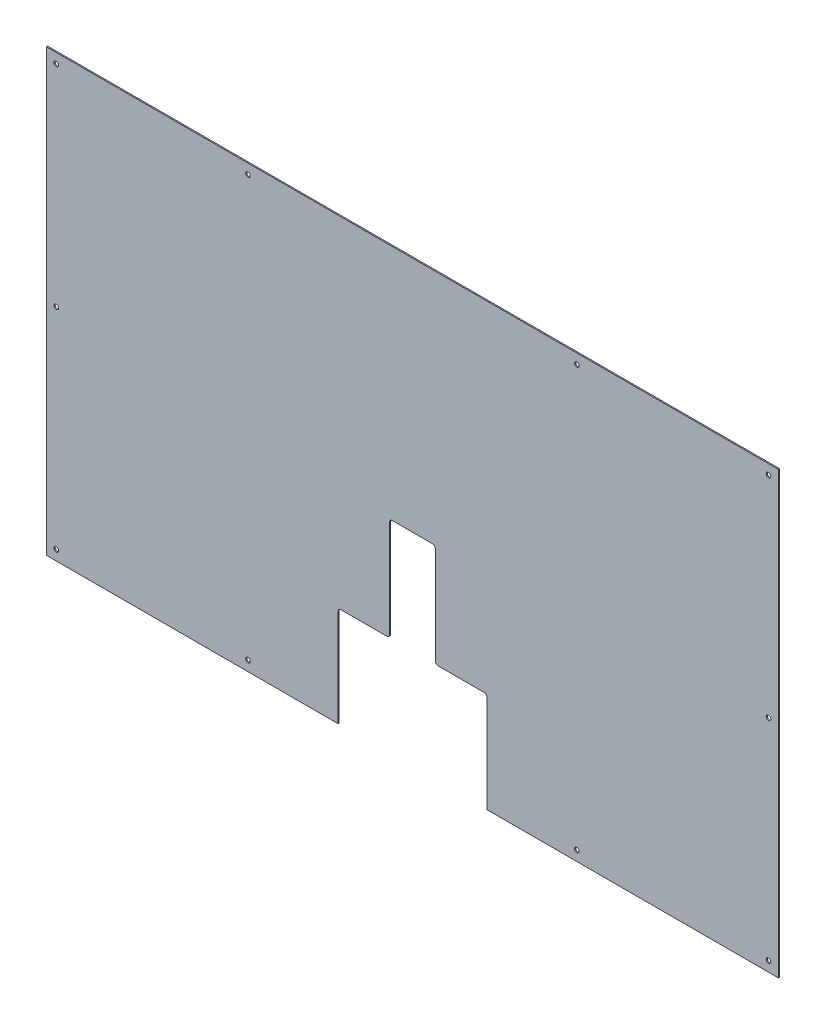
from build123d import *

# Parameters (mm, degrees)
SKETCH1_R           = 4
BOSS_EXTRUDE1_DEPTH = 2


with BuildPart() as part:
    # Sketch1 → Boss-Extrude1 (new body)
    with BuildSketch(Plane.XY):
        with BuildLine():
            Line((0, 0), (0, 770))
            Line((0, 770), (1280, 770))
            Line((1280, 770), (1280, 0))
            Line((1280, 0), (770, 0))
            Line((770, 0), (770, 170))
            ThreePointArc((770, 170), (768.535533906, 173.535533906), (765, 175))
            Line((765, 175), (685, 175))
            ThreePointArc((685, 175), (681.464466094, 176.464466094), (680, 180))
            Line((680, 180), (680, 350))
            ThreePointArc((680, 350), (678.535533906, 353.535533906), (675, 355))
            Line((675, 355), (605, 355))
            ThreePointArc((605, 355), (601.464466094, 353.535533906), (600, 350))
            Line((600, 350), (600, 180))
            ThreePointArc((600, 180), (598.535533906, 176.464466094), (595, 175))
            Line((595, 175), (515, 175))
            ThreePointArc((515, 175), (511.464466094, 173.535533906), (510, 170))
            Line((510, 170), (510, 0))
            Line((510, 0), (0, 0))
        make_face()
        with Locations((17.5, 752.5)):
            Circle(SKETCH1_R, mode=Mode.SUBTRACT)
        with Locations(Location((1262.5, 752.5, 0), (0, 0, 180))):  # turned: the seam where the file's is
            Circle(SKETCH1_R, mode=Mode.SUBTRACT)
        with Locations((1262.5, 17.5)):
            Circle(SKETCH1_R, mode=Mode.SUBTRACT)
        with Locations(Location((17.5, 17.5, 0), (0, 0, 180))):  # turned: the seam where the file's is
            Circle(SKETCH1_R, mode=Mode.SUBTRACT)
        with Locations((352.5, 752.5)):
            Circle(SKETCH1_R, mode=Mode.SUBTRACT)
        with Locations(Location((927.5, 752.5, 0), (0, 0, 180))):  # turned: the seam where the file's is
            Circle(SKETCH1_R, mode=Mode.SUBTRACT)
        with Locations((927.5, 17.5)):
            Circle(SKETCH1_R, mode=Mode.SUBTRACT)
        with Locations(Location((352.5, 17.5, 0), (0, 0, 180))):  # turned: the seam where the file's is
            Circle(SKETCH1_R, mode=Mode.SUBTRACT)
        with Locations((17.5, 385)):
            Circle(SKETCH1_R, mode=Mode.SUBTRACT)
        with Locations(Location((1262.5, 385, 0), (0, 0, 180))):  # turned: the seam where the file's is
            Circle(SKETCH1_R, mode=Mode.SUBTRACT)
    extrude(amount=BOSS_EXTRUDE1_DEPTH)


solid = part.part
